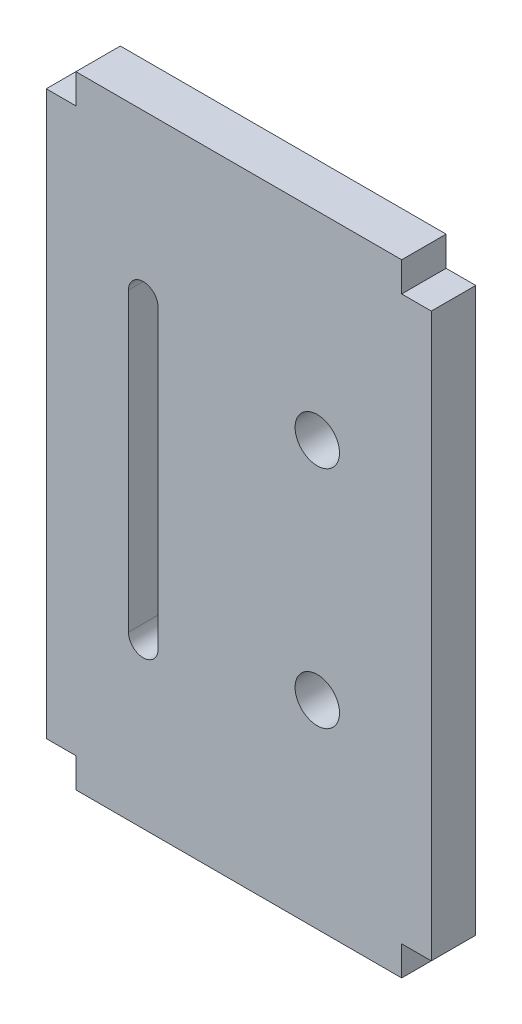
from build123d import *

# Parameters (mm, degrees)
SKETCH_1_W          = 22
SKETCH_1_H          = 42
SKETCH_1_W_2        = 2
SKETCH_1_H_2        = 38
EXTRUDE_1_DEPTH     = 3
SKETCH_2_R          = 1.5
CUT_EXTRUDE_1_DEPTH = 10


with BuildPart() as part:
    # 草图1 → 凸台-拉伸1 (new body)
    with BuildSketch(Plane.XY):
        Rectangle(SKETCH_1_W, SKETCH_1_H)
        with Locations((-12, 0)):
            Rectangle(SKETCH_1_W_2, SKETCH_1_H_2)
        with Locations((12, 0)):
            Rectangle(SKETCH_1_W_2, SKETCH_1_H_2)
    extrude(amount=EXTRUDE_1_DEPTH)

    # 草图2 → 切除-拉伸1 (cut)
    with BuildSketch(Plane.XY.offset(3)):
        with Locations((5.3, -7.6)):
            Circle(SKETCH_2_R)
        with Locations((5.3, 7.6)):
            Circle(SKETCH_2_R)
        with BuildLine():
            Line((-7.45, -10), (-7.45, 10))
            ThreePointArc((-7.45, 10), (-6.45, 11), (-5.45, 10))
            Line((-5.45, 10), (-5.45, -10))
            ThreePointArc((-5.45, -10), (-6.45, -11), (-7.45, -10))
        make_face()
    extrude(amount=-CUT_EXTRUDE_1_DEPTH, mode=Mode.SUBTRACT)


solid = part.part
